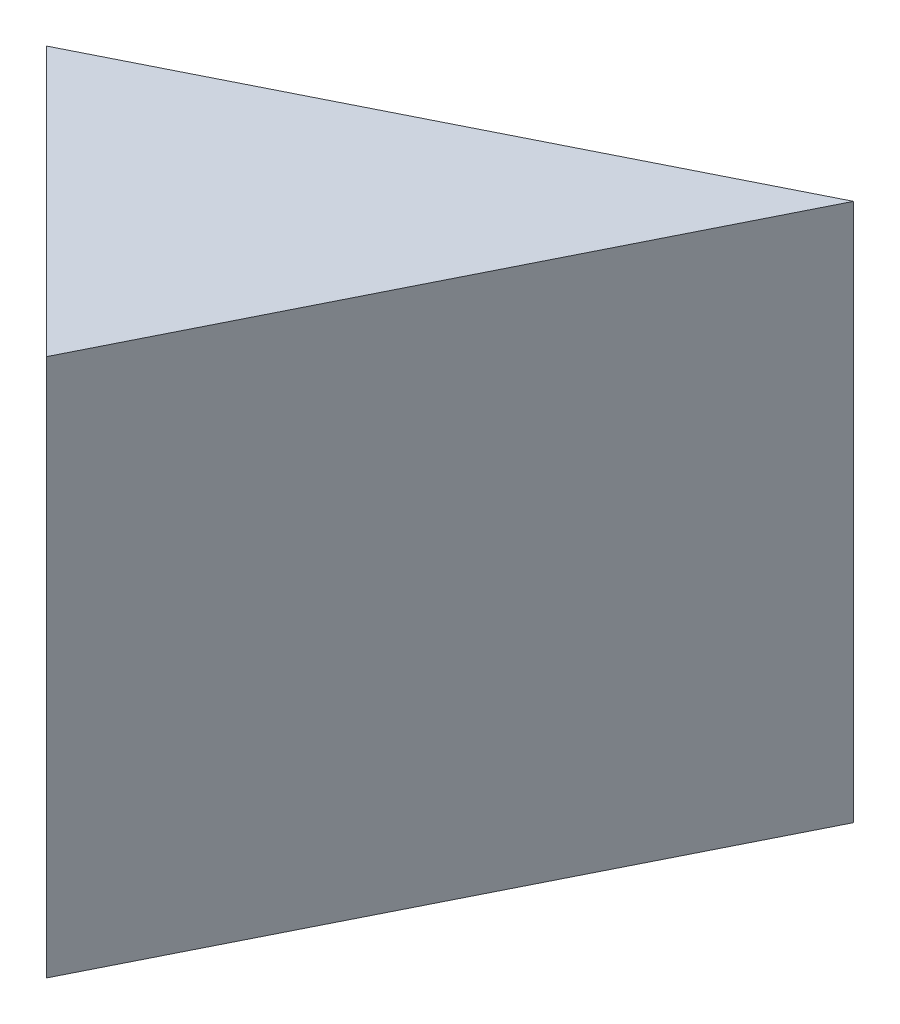
from build123d import *

# Parameters (mm, degrees)
SKETCH1_W           = 20
SKETCH1_H           = 20
BOSS_EXTRUDE1_DEPTH = 20
CUT_EXTRUDE1_DEPTH  = 20
CUT_EXTRUDE2_DEPTH  = 20
CUT_EXTRUDE3_DEPTH  = 20


with BuildPart() as part:
    # Sketch1 → Boss-Extrude1 (new body)
    with BuildSketch(Plane.XY):
        with Locations((10, 10)):
            Rectangle(SKETCH1_W, SKETCH1_H)
    extrude(amount=BOSS_EXTRUDE1_DEPTH)

    # Sketch2 → Cut-Extrude1 (cut)
    with BuildSketch(Plane(origin=(0, 20, 0), x_dir=(1, 0, 0), z_dir=(0, 1, 0))):
        Polygon((20, 0), (10, -20), (20, -20), align=None)
    extrude(amount=-CUT_EXTRUDE1_DEPTH, mode=Mode.SUBTRACT)

    # Sketch3 → Cut-Extrude2 (cut)
    with BuildSketch(Plane(origin=(0, 20, 0), x_dir=(1, 0, 0), z_dir=(0, 1, 0))):
        Polygon((0, -20), (10, -20), (0, -10), align=None)
    extrude(amount=-CUT_EXTRUDE2_DEPTH, mode=Mode.SUBTRACT)

    # Sketch4 → Cut-Extrude3 (cut)
    with BuildSketch(Plane(origin=(0, 20, 0), x_dir=(1, 0, 0), z_dir=(0, 1, 0))):
        Polygon((20, 0), (0, -10), (0, 0), align=None)
    extrude(amount=-CUT_EXTRUDE3_DEPTH, mode=Mode.SUBTRACT)


solid = part.part
